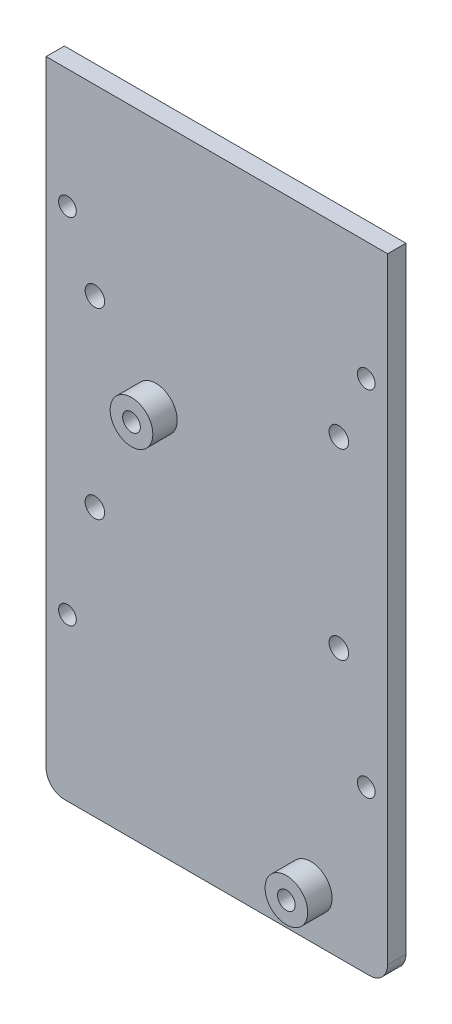
from build123d import *

# Parameters (mm, degrees)
BOSS_EXTRUDE1_DEPTH = 3
SKETCH3_R           = 1.6
SKETCH3_R_2         = 1.45
CUT_EXTRUDE1_DEPTH  = 89.191303006
SKETCH4_R           = 3.5
SKETCH4_R_2         = 1.45
BOSS_EXTRUDE2_DEPTH = 4


with BuildPart() as part:
    # Sketch2 → Boss-Extrude1 (new body)
    with BuildSketch(Plane.XY):
        with BuildLine():
            Line((-55.566838563, -38.131712133), (-5.566838563, -38.131712133))
            ThreePointArc((-5.566838563, -38.131712133), (-3.44551822, -37.253032477), (-2.566838563, -35.131712133))
            Line((-2.566838563, -35.131712133), (-2.566838563, 65.868287867))
            Line((-2.566838563, 65.868287867), (-58.566838563, 65.868287867))
            Line((-58.566838563, 65.868287867), (-58.566838563, -35.131712133))
            ThreePointArc((-58.566838563, -35.131712133), (-57.688158907, -37.253032477), (-55.566838563, -38.131712133))
        make_face()
    extrude(amount=BOSS_EXTRUDE1_DEPTH)

    # Sketch3 → Cut-Extrude1 (cut, through all)
    with BuildSketch(Plane.XY.offset(3)):
        with Locations((-50.566838563, 35.868287867)):
            Circle(SKETCH3_R)
        with Locations((-50.566838563, 5.868287867)):
            Circle(SKETCH3_R)
        with Locations(Location((-10.566838563, 5.868287867, 0), (0, 0, 180))):
            Circle(SKETCH3_R)
        with Locations(Location((-10.566838563, 35.868287867, 0), (0, 0, 180))):
            Circle(SKETCH3_R)
        with Locations((-40.566838563, 24.968287867)):
            Circle(SKETCH3_R_2)
        with Locations((-15.166838563, -30.231712133)):
            Circle(SKETCH3_R_2)
        with Locations((-6.066838563, 46.368287867)):
            Circle(SKETCH3_R_2)
        with Locations((-6.066838563, -11.631712133)):
            Circle(SKETCH3_R_2)
        with Locations(Location((-55.066838563, -11.631712133, 0), (0, 0, 180))):
            Circle(SKETCH3_R_2)
        with Locations(Location((-55.066838563, 46.368287867, 0), (0, 0, 180))):
            Circle(SKETCH3_R_2)
    extrude(amount=-CUT_EXTRUDE1_DEPTH, mode=Mode.SUBTRACT)

    # Sketch4 → Boss-Extrude2 (add)
    with BuildSketch(Plane.XY.offset(3)):
        with Locations((-40.566838563, 24.968287867)):
            Circle(SKETCH4_R)
        with Locations((-40.566838563, 24.968287867)):
            Circle(SKETCH4_R_2, mode=Mode.SUBTRACT)
        with Locations((-15.166838563, -30.231712133)):
            Circle(SKETCH4_R)
        with Locations((-15.166838563, -30.231712133)):
            Circle(SKETCH4_R_2, mode=Mode.SUBTRACT)
    extrude(amount=BOSS_EXTRUDE2_DEPTH)


solid = part.part
